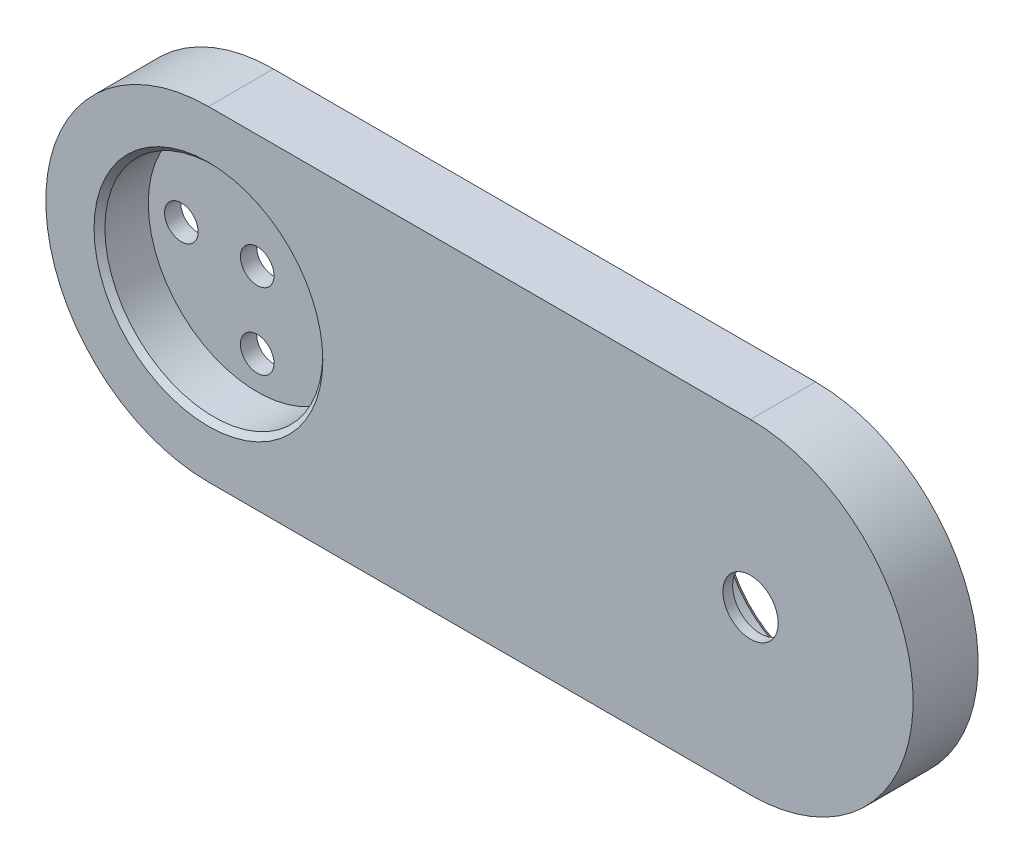
from build123d import *

# Parameters (mm, degrees)
BOSS_EXTRUDE1_DEPTH = 6
SKETCH8_R           = 10.05
CUT_EXTRUDE4_DEPTH  = 4.5
SKETCH9_R           = 7.975
CUT_EXTRUDE5_DEPTH  = 5.1
SKETCH10_R          = 2.55
CUT_EXTRUDE6_DEPTH  = 1.9
SKETCH11_R          = 1.55
CUT_EXTRUDE7_DEPTH  = 2.5
CHAMFER1_SIZE       = 0.5


with BuildPart() as part:
    # Sketch4 → Boss-Extrude1 (new body)
    with BuildSketch(Plane.XY):
        with BuildLine():
            Line((-25, 15), (25, 15))
            ThreePointArc((25, 15), (40, 0), (25, -15))
            Line((25, -15), (-25, -15))
            ThreePointArc((-25, -15), (-40, 0), (-25, 15))
        make_face()
    extrude(amount=BOSS_EXTRUDE1_DEPTH)

    # Sketch8 → Cut-Extrude4 (cut)
    with BuildSketch(Plane.XY.offset(6)):
        with Locations((-25, 0)):
            Circle(SKETCH8_R)
    extrude(amount=-CUT_EXTRUDE4_DEPTH, mode=Mode.SUBTRACT)

    # Sketch9 → Cut-Extrude5 (cut)
    with BuildSketch(Plane(origin=(0, 0, 0), x_dir=(-1, 0, 0), z_dir=(0, 0, -1))):
        with Locations((-25, 0)):
            Circle(SKETCH9_R)
    extrude(amount=-CUT_EXTRUDE5_DEPTH, mode=Mode.SUBTRACT)

    # Sketch10 → Cut-Extrude6 (cut, through all)
    with BuildSketch(Plane(origin=(0, 0, 5.1), x_dir=(-1, 0, 0), z_dir=(0, 0, -1))):
        with Locations((-25, 0)):
            Circle(SKETCH10_R)
    extrude(amount=-CUT_EXTRUDE6_DEPTH, mode=Mode.SUBTRACT)

    # Sketch11 → Cut-Extrude7 (cut, through all)
    with BuildSketch(Plane.XY.offset(1.5)):
        with Locations((-25, 0)):
            Circle(SKETCH11_R)
        with Locations((-18, 0)):
            Circle(SKETCH11_R)
        with Locations((-32, 0)):
            Circle(SKETCH11_R)
        with Locations((-25, 7)):
            Circle(SKETCH11_R)
        with Locations((-25, -7)):
            Circle(SKETCH11_R)
    extrude(amount=-CUT_EXTRUDE7_DEPTH, mode=Mode.SUBTRACT)

    # Chamfer1
    chamfer1_edges = [part.edges().sort_by_distance(p)[0] for p in [
        (-35.05, 0, 6),
        (32.975, 0, 0),
    ]]
    chamfer(chamfer1_edges, length=CHAMFER1_SIZE)


solid = part.part
